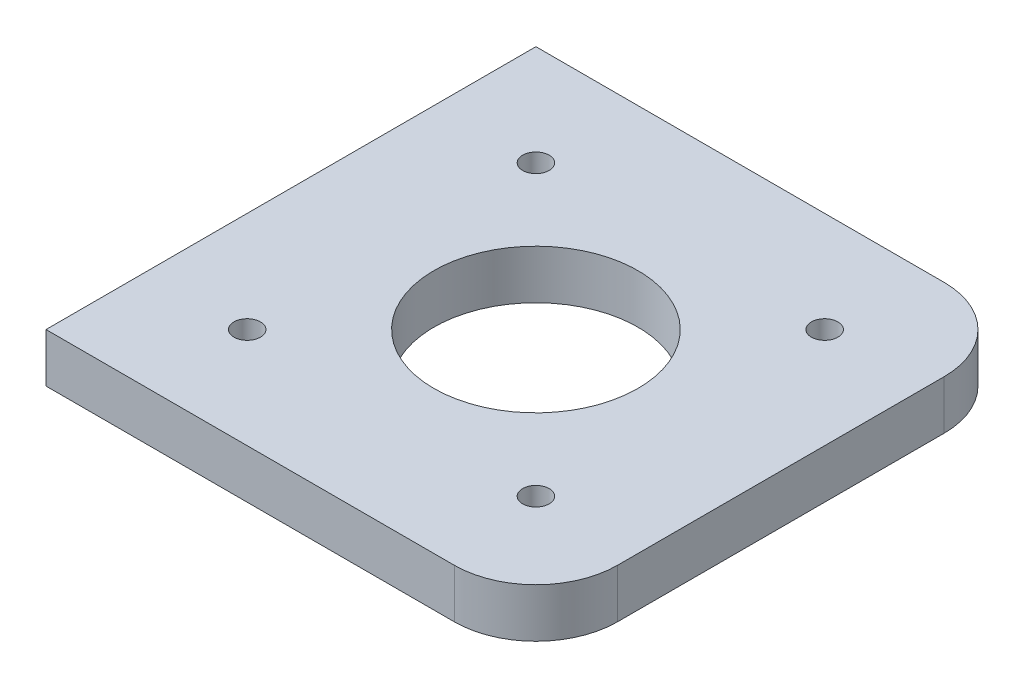
from build123d import *

# Parameters (mm, degrees)
SKETCH1_W           = 60
SKETCH1_H           = 60
SKETCH1_R           = 1.625
SKETCH1_R_2         = 12.5
BOSS_EXTRUDE1_DEPTH = 6
FILLET1_R           = 10


with BuildPart() as part:
    # Sketch1 → Boss-Extrude1 (new body)
    with BuildSketch(Plane(origin=(0, 0, 0), x_dir=(1, 0, 0), z_dir=(0, 1, 0))):
        with Locations((17.68, 17.68)):
            Rectangle(SKETCH1_W, SKETCH1_H)
        with Locations((0, 35.36)):
            Circle(SKETCH1_R, mode=Mode.SUBTRACT)
        with Locations((35.36, 35.36)):
            Circle(SKETCH1_R, mode=Mode.SUBTRACT)
        with Locations((35.36, 0)):
            Circle(SKETCH1_R, mode=Mode.SUBTRACT)
        Circle(SKETCH1_R, mode=Mode.SUBTRACT)
        with Locations((17.68, 17.68)):
            Circle(SKETCH1_R_2, mode=Mode.SUBTRACT)
    extrude(amount=BOSS_EXTRUDE1_DEPTH)

    # Fillet1
    fillet1_edges = [part.edges().sort_by_distance(p)[0] for p in [
        (47.68, 3, -47.68),
        (47.68, 3, 12.32),
    ]]
    fillet(fillet1_edges, radius=FILLET1_R)


solid = part.part
